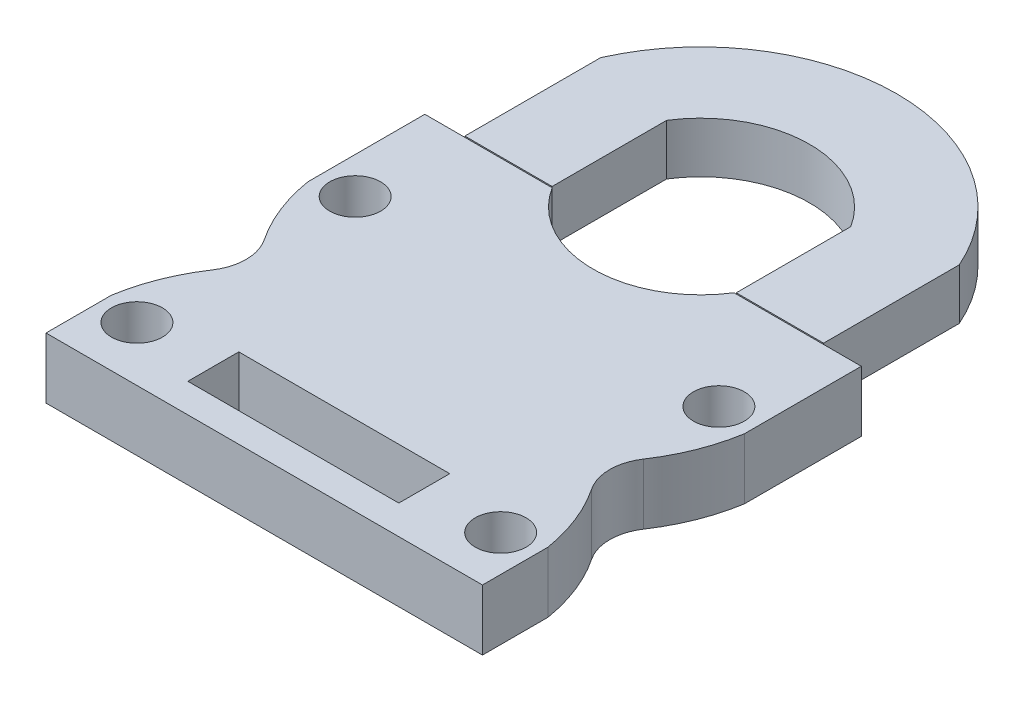
from build123d import *

# Parameters (mm, degrees)
SKETCH1_R            = 2.85115
BOSS_EXTRUDE1_DEPTH  = 10.6045
SKETCH2_R            = 4.445
CUT_EXTRUDE1_DEPTH   = 7.9121
SKETCH3_W            = 9.525
SKETCH3_H            = 7.4295
CUT_EXTRUDE2_DEPTH   = 38.1
CUT_EXTRUDE7_DEPTH   = 5.715
BOSS_EXTRUDE3_DEPTH  = 3.5647503
SKETCH13_W           = 36.83
SKETCH13_H           = 8.89
CUT_EXTRUDE10_DEPTH  = 11.6045
MIRROR6_COPY_1_DEPTH = 5.715
BOSS_EXTRUDE5_DEPTH  = 1.7375


with BuildPart() as part:
    # Sketch1 → Boss-Extrude1 (new body)
    with BuildSketch(Plane(origin=(0, 0, 0), x_dir=(1, 0, 0), z_dir=(0, 1, 0))):
        with BuildLine():
            Line((-38.1, -28.575), (38.1, -28.575))
            Line((38.1, -28.575), (38.1, 37.561502049))
            Line((38.1, 37.561502049), (15.875, 37.561502049))
            ThreePointArc((15.875, 37.561502049), (0, 28.829), (-15.875, 37.561502049))
            Line((-15.875, 37.561502049), (-38.1, 37.561502049))
            Line((-38.1, 37.561502049), (-38.1, -28.575))
        make_face()
        with Locations((-31.75, 19.05)):
            Circle(SKETCH1_R, mode=Mode.SUBTRACT)
        with Locations((31.75, 19.05)):
            Circle(SKETCH1_R, mode=Mode.SUBTRACT)
        with Locations((31.75, -19.05)):
            Circle(SKETCH1_R, mode=Mode.SUBTRACT)
        with Locations((-31.75, -19.05)):
            Circle(SKETCH1_R, mode=Mode.SUBTRACT)
    extrude(amount=BOSS_EXTRUDE1_DEPTH)

    # Sketch2 → Cut-Extrude1 (cut)
    with BuildSketch(Plane(origin=(0, 10.6045, 0), x_dir=(1, 0, 0), z_dir=(0, 1, 0))):
        with Locations((-31.75, 19.05)):
            Circle(SKETCH2_R)
        with Locations((31.75, 19.05)):
            Circle(SKETCH2_R)
        with Locations((31.75, -19.05)):
            Circle(SKETCH2_R)
        with Locations((-31.75, -19.05)):
            Circle(SKETCH2_R)
    extrude(amount=-CUT_EXTRUDE1_DEPTH, mode=Mode.SUBTRACT)

    # Sketch3 → Cut-Extrude2 (cut)
    with BuildSketch(Plane(origin=(0, 0, -37.561502049), x_dir=(-1, 0, 0), z_dir=(0, 0, -1))):
        with Locations((20.6375, 5.30225)):
            Rectangle(SKETCH3_W, SKETCH3_H)
    cut_extrude2 = extrude(amount=-CUT_EXTRUDE2_DEPTH, mode=Mode.SUBTRACT)

    # Mirror1: Cut-Extrude2 across plane
    add(cut_extrude2.mirror(Plane(origin=(0, 0, 0), x_dir=(0, 0, 1), z_dir=(1, 0, 0))), mode=Mode.SUBTRACT)

    # Sketch7 → Cut-Extrude7 (cut, symmetric)
    with BuildSketch(Plane(origin=(0, 5.30225, 0), x_dir=(1, 0, 0), z_dir=(0, 1, 0))):
        with BuildLine():
            Line((-38.1, 17.145), (-38.1, 0))
            Line((-38.1, 0), (-31.75, 0))
            ThreePointArc((-31.75, 0), (-32.10199393, 2.372518284), (-33.127651434, 4.540644068))
            ThreePointArc((-33.127651434, 4.540644068), (-36.288841608, 10.576532006), (-38.1, 17.145))
        make_face()
    cut_extrude7 = extrude(amount=CUT_EXTRUDE7_DEPTH, both=True, mode=Mode.SUBTRACT)

    # Mirror4: Cut-Extrude7 across plane
    add(cut_extrude7.mirror(Plane(origin=(0, 0, 0), x_dir=(0, 0, 1), z_dir=(1, 0, 0))), mode=Mode.SUBTRACT)

    # Sketch13 → Cut-Extrude10 (cut, through all)
    with BuildSketch(Plane(origin=(0, 10.6045, 0), x_dir=(1, 0, 0), z_dir=(0, 1, 0))):
        with Locations((0, -19.05)):
            Rectangle(SKETCH13_W, SKETCH13_H)
    extrude(amount=-CUT_EXTRUDE10_DEPTH, mode=Mode.SUBTRACT)

    # Mirror6: Cut-Extrude7 across plane
    add(cut_extrude7.mirror(Plane.XY), mode=Mode.SUBTRACT)

    # Mirror6 copy 1 sketch → Mirror6 copy 1 (cut, symmetric)
    with BuildSketch(Plane(origin=(0, 5.30225, 0), x_dir=(-1, 0, 0), z_dir=(0, 1, 0))):
        with BuildLine():
            Line((-38.1, 17.145), (-38.1, 0))
            Line((-38.1, 0), (-31.75, 0))
            ThreePointArc((-31.75, 0), (-32.10199393, 2.372518284), (-33.127651434, 4.540644068))
            ThreePointArc((-33.127651434, 4.540644068), (-36.288841608, 10.576532006), (-38.1, 17.145))
        make_face()
    extrude(amount=MIRROR6_COPY_1_DEPTH, both=True, mode=Mode.SUBTRACT)


with BuildPart() as body_2:
    # Sketch8 → Boss-Extrude3 (new body, symmetric)
    with BuildSketch(Plane(origin=(0, 5.30225, 0), x_dir=(1, 0, 0), z_dir=(0, 1, 0))):
        with BuildLine():
            Line((16.0734375, 57.745931917), (16.0734375, 37.759939549))
            Line((16.0734375, 37.759939549), (16.0734375, 0))
            Line((16.0734375, 0), (25.2015625, 0))
            Line((25.2015625, 0), (25.2015625, 37.759939549))
            Line((25.2015625, 37.759939549), (31.3134375, 37.759939549))
            Line((31.3134375, 37.759939549), (31.3134375, 61.462100234))
            ThreePointArc((31.3134375, 61.462100234), (0, 81.8594375), (-31.3134375, 61.462100234))
            Line((-31.3134375, 61.462100234), (-31.3134375, 37.759939549))
            Line((-31.3134375, 37.759939549), (-25.2015625, 37.759939549))
            Line((-25.2015625, 37.759939549), (-25.2015625, 0))
            Line((-25.2015625, 0), (-16.0734375, 0))
            Line((-16.0734375, 0), (-16.0734375, 37.759939549))
            Line((-16.0734375, 37.759939549), (-16.0734375, 57.745931917))
            ThreePointArc((-16.0734375, 57.745931917), (0, 66.6194375), (16.0734375, 57.745931917))
        make_face()
    extrude(amount=BOSS_EXTRUDE3_DEPTH, both=True)

    # Sketch18 → Boss-Extrude5 (add)
    with BuildSketch(Plane(origin=(0, 8.8670003, 0), x_dir=(1, 0, 0), z_dir=(0, 1, 0))):
        with BuildLine():
            Line((-31.3134375, 37.759939549), (-16.0734375, 37.759939549))
            Line((-16.0734375, 37.759939549), (-16.0734375, 57.745931917))
            ThreePointArc((-16.0734375, 57.745931917), (0, 66.6194375), (16.0734375, 57.745931917))
            Line((16.0734375, 57.745931917), (16.0734375, 37.759939549))
            Line((16.0734375, 37.759939549), (31.3134375, 37.759939549))
            Line((31.3134375, 37.759939549), (31.3134375, 61.462100234))
            ThreePointArc((31.3134375, 61.462100234), (0, 81.8594375), (-31.3134375, 61.462100234))
            Line((-31.3134375, 61.462100234), (-31.3134375, 37.759939549))
        make_face()
    extrude(amount=BOSS_EXTRUDE5_DEPTH)


solid = Compound([part.part, body_2.part])
